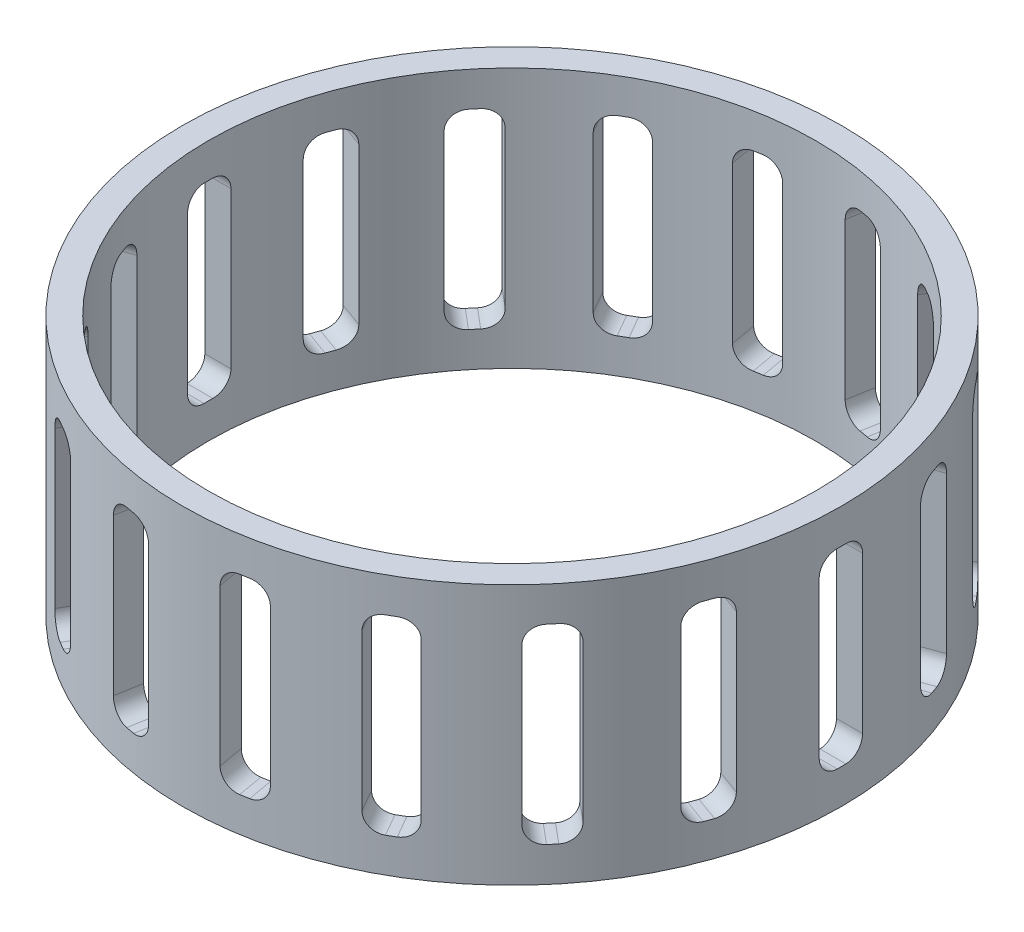
from build123d import *

# Parameters (mm, degrees)
SZKIC1_W                        = 3
SZKIC1_H                        = 30
WYTNIJ_WYCI_GNI_CIE1_START      = -38
SZKIC2_W                        = 5
SZKIC2_H                        = 22
WYTNIJ_WYCI_GNI_CIE1_DEPTH      = 3.0894
ZAOKR_GLENIE1_R                 = 2
SZYK_KO_OWY1_COUNT              = 18
ZAOKR_GLENIE1_OF_SZYK_KO_OWY1_R = 2


with BuildPart() as part:
    # Szkic1 → Obrót1 (revolve)
    with BuildSketch(Plane.XY):
        with Locations((-36.5, 0)):
            Rectangle(SZKIC1_W, SZKIC1_H)
    revolve(axis=Axis((0, -11.541666667, 0), (0, 1, 0)))

    # Szkic2 → Wytnij-wyciągnięcie1 (cut)
    with BuildSketch(Plane(origin=(0, 0, 0), x_dir=(0, 0, -1), z_dir=(1, 0, 0)).offset(WYTNIJ_WYCI_GNI_CIE1_START)):
        Rectangle(SZKIC2_W, SZKIC2_H)
    wytnij_wyci_gni_cie1 = extrude(amount=WYTNIJ_WYCI_GNI_CIE1_DEPTH, mode=Mode.SUBTRACT)

    # Zaokrąglenie1
    zaokr_glenie1_edges = [part.edges().sort_by_distance(p)[0] for p in [
        (-36.41413699, -11, -2.5),
        (-36.41413699, -11, 2.5),
        (-36.41413699, 11, 2.5),
        (-36.41413699, 11, -2.5),
    ]]
    fillet(zaokr_glenie1_edges, radius=ZAOKR_GLENIE1_R)

    # Szyk kołowy1: Wytnij-wyciągnięcie1 ×18 about axis
    szyk_ko_owy1_axis = Axis((0, 0, 0), (0, 1, 0))
    for i in range(1, SZYK_KO_OWY1_COUNT):
        add(wytnij_wyci_gni_cie1.rotate(szyk_ko_owy1_axis, i * 360 / SZYK_KO_OWY1_COUNT), mode=Mode.SUBTRACT)

    # Zaokrąglenie1 of Szyk kołowy1
    zaokr_glenie1_of_szyk_ko_owy1_edges = [part.edges().sort_by_distance(p)[0] for p in [
        (-35.07314618, -11, 10.1051368),
        (-33.363045463, -11, 14.803599904),
        (-33.363045463, 11, 14.803599904),
        (-35.07314618, 11, 10.1051368),
        (-29.501816316, -11, 21.491444967),
        (-26.287878268, -11, 25.321667182),
        (-26.287878268, 11, 25.321667182),
        (-29.501816316, 11, 21.491444967),
        (-20.372132004, -11, 30.28556769),
        (-16.042004985, -11, 32.78556769),
        (-16.042004985, 11, 32.78556769),
        (-20.372132004, 11, 30.28556769),
        (-8.785267912, -11, 35.426803982),
        (-3.861229147, -11, 36.295044871),
        (-3.861229147, 11, 36.295044871),
        (-8.785267912, 11, 35.426803982),
        (3.861229147, -11, 36.295044871),
        (8.785267912, -11, 35.426803982),
        (8.785267912, 11, 35.426803982),
        (3.861229147, 11, 36.295044871),
        (16.042004985, -11, 32.78556769),
        (20.372132004, -11, 30.28556769),
        (20.372132004, 11, 30.28556769),
        (16.042004985, 11, 32.78556769),
        (26.287878268, -11, 25.321667182),
        (29.501816316, -11, 21.491444967),
        (29.501816316, 11, 21.491444967),
        (26.287878268, 11, 25.321667182),
        (33.363045463, -11, 14.803599904),
        (35.07314618, -11, 10.1051368),
        (35.07314618, 11, 10.1051368),
        (33.363045463, 11, 14.803599904),
        (36.41413699, -11, 2.5),
        (36.41413699, -11, -2.5),
        (36.41413699, 11, -2.5),
        (36.41413699, 11, 2.5),
        (35.07314618, -11, -10.1051368),
        (33.363045463, -11, -14.803599904),
        (33.363045463, 11, -14.803599904),
        (35.07314618, 11, -10.1051368),
        (29.501816316, -11, -21.491444967),
        (26.287878268, -11, -25.321667182),
        (26.287878268, 11, -25.321667182),
        (29.501816316, 11, -21.491444967),
        (20.372132004, -11, -30.28556769),
        (16.042004985, -11, -32.78556769),
        (16.042004985, 11, -32.78556769),
        (20.372132004, 11, -30.28556769),
        (8.785267912, -11, -35.426803982),
        (3.861229147, -11, -36.295044871),
        (3.861229147, 11, -36.295044871),
        (8.785267912, 11, -35.426803982),
        (-3.861229147, -11, -36.295044871),
        (-8.785267912, -11, -35.426803982),
        (-8.785267912, 11, -35.426803982),
        (-3.861229147, 11, -36.295044871),
        (-16.042004985, -11, -32.78556769),
        (-20.372132004, -11, -30.28556769),
        (-20.372132004, 11, -30.28556769),
        (-16.042004985, 11, -32.78556769),
        (-26.287878268, -11, -25.321667182),
        (-29.501816316, -11, -21.491444967),
        (-29.501816316, 11, -21.491444967),
        (-26.287878268, 11, -25.321667182),
        (-33.363045463, -11, -14.803599904),
        (-35.07314618, -11, -10.1051368),
        (-35.07314618, 11, -10.1051368),
        (-33.363045463, 11, -14.803599904),
    ]]
    fillet(zaokr_glenie1_of_szyk_ko_owy1_edges, radius=ZAOKR_GLENIE1_OF_SZYK_KO_OWY1_R)


solid = part.part
